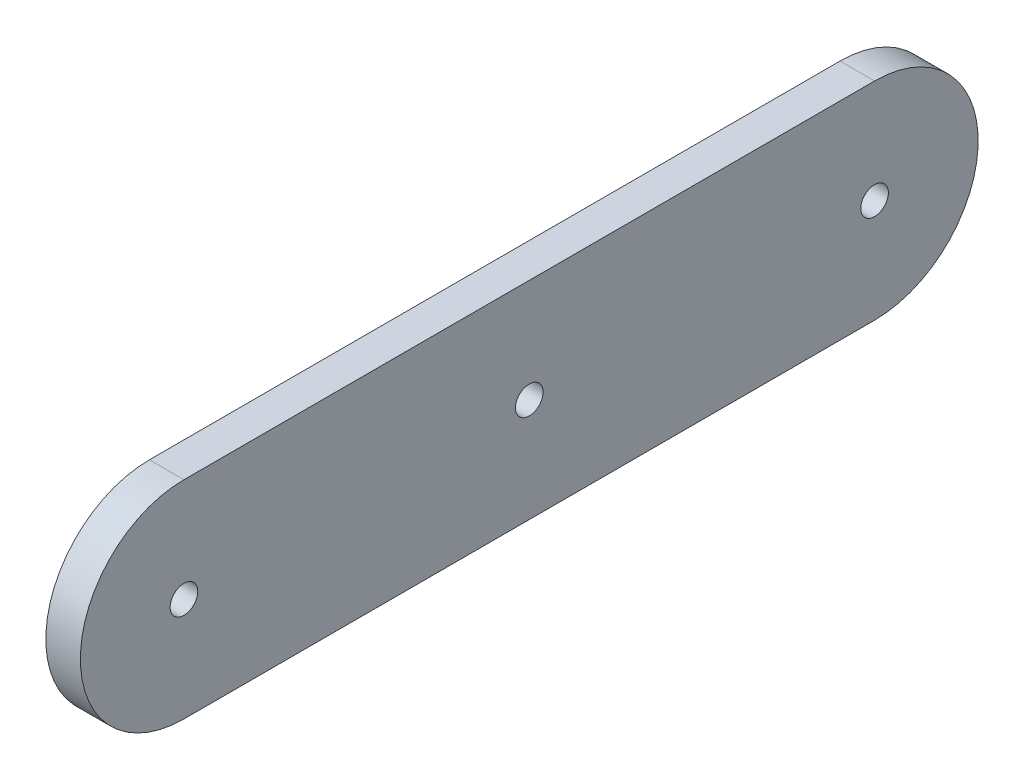
from build123d import *

# Parameters (mm, degrees)
ESTRUSIONE_ESTRUSIONE1_DEPTH = 5
SCHIZZO2_R                   = 2
TAGLIO_ESTRUSIONE1_DEPTH     = 6


with BuildPart() as part:
    # Schizzo1 → Estrusione-Estrusione1 (new body)
    with BuildSketch(Plane(origin=(0, 0, 0), x_dir=(0, 0, -1), z_dir=(1, 0, 0))):
        with BuildLine():
            Line((-50, 15), (50, 15))
            ThreePointArc((50, 15), (65, 0), (50, -15))
            Line((50, -15), (-50, -15))
            ThreePointArc((-50, -15), (-65, 0), (-50, 15))
        make_face()
    extrude(amount=ESTRUSIONE_ESTRUSIONE1_DEPTH)

    # Schizzo2 → Taglio-Estrusione1 (cut, through all)
    with BuildSketch(Plane(origin=(5, 0, 0), x_dir=(0, 0, -1), z_dir=(1, 0, 0))):
        with Locations((-50, 0)):
            Circle(SCHIZZO2_R)
        Circle(SCHIZZO2_R)
        with Locations((50, 0)):
            Circle(SCHIZZO2_R)
    extrude(amount=-TAGLIO_ESTRUSIONE1_DEPTH, mode=Mode.SUBTRACT)


solid = part.part
